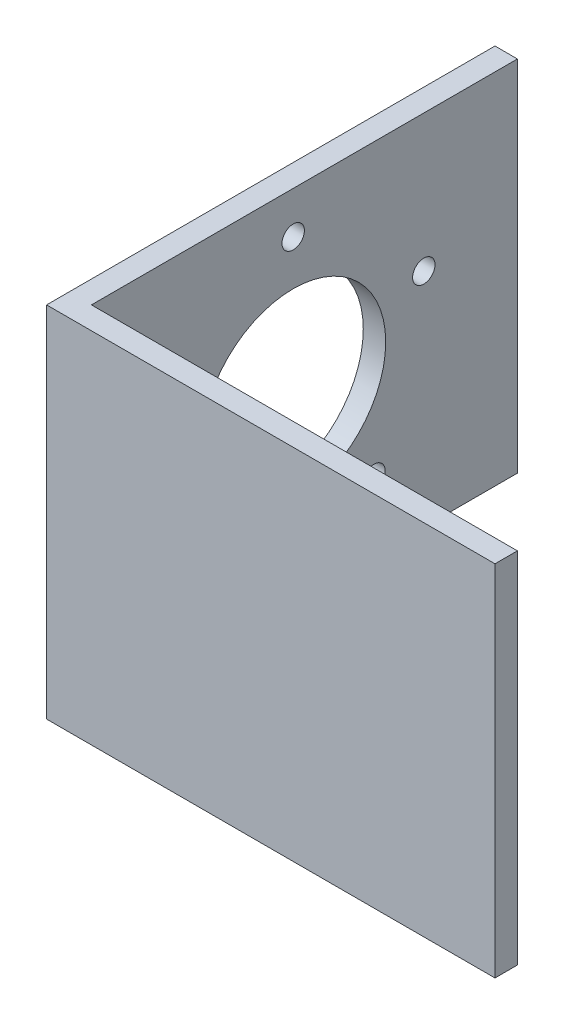
from build123d import *

# Parameters (mm, degrees)
BOSS_EXTRUDE1_DEPTH = 50.8
SKETCH2_R           = 26.19375
CUT_EXTRUDE1_DEPTH  = 128
SKETCH3_R           = 3.175
CUT_EXTRUDE2_DEPTH  = 128
CIRPATTERN1_COUNT   = 5


with BuildPart() as part:
    # Sketch1 → Boss-Extrude1 (new body, symmetric)
    with BuildSketch(Plane(origin=(0, 0, 0), x_dir=(1, 0, 0), z_dir=(0, 1, 0))):
        Polygon((0, 63.5), (6.35, 63.5), (6.35, -57.15), (127, -57.15), (127, -63.5), (0, -63.5), align=None)
    extrude(amount=BOSS_EXTRUDE1_DEPTH, both=True)

    # Sketch2 → Cut-Extrude1 (cut, through all)
    with BuildSketch(Plane.ZY):
        Circle(SKETCH2_R)
    extrude(amount=-CUT_EXTRUDE1_DEPTH, mode=Mode.SUBTRACT)

    # Sketch3 → Cut-Extrude2 (cut, through all)
    with BuildSketch(Plane.ZY):
        with Locations((0, 38.89375)):
            Circle(SKETCH3_R)
    cut_extrude2 = extrude(amount=-CUT_EXTRUDE2_DEPTH, mode=Mode.SUBTRACT)

    # CirPattern1: Cut-Extrude2 ×5 about axis
    cirpattern1_axis = Axis((0, 0, 0), (1, 0, 0))
    for i in range(1, CIRPATTERN1_COUNT):
        add(cut_extrude2.rotate(cirpattern1_axis, i * 360 / CIRPATTERN1_COUNT), mode=Mode.SUBTRACT)


solid = part.part
